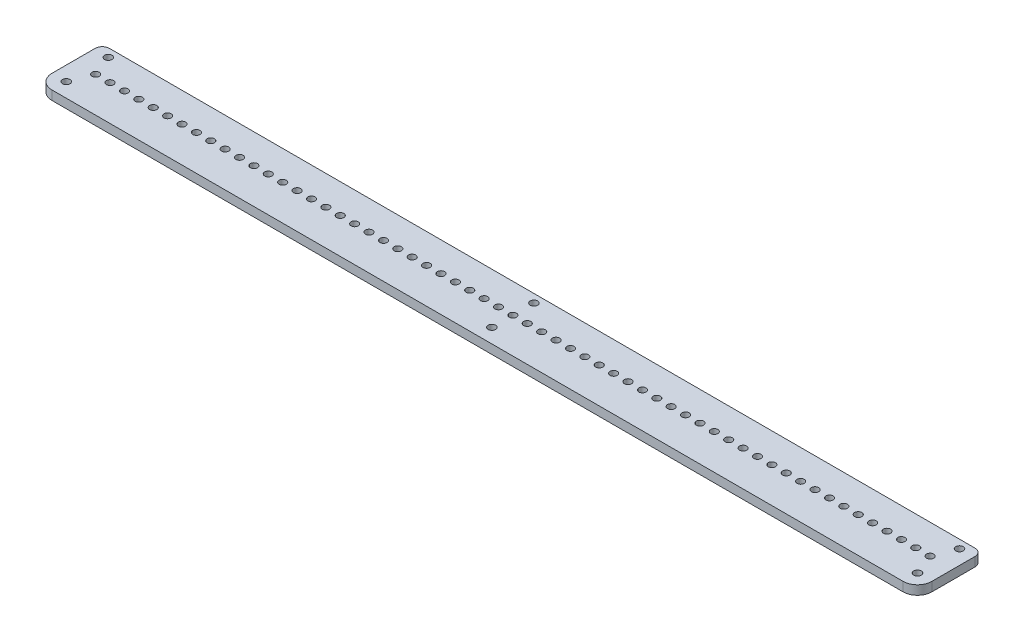
from build123d import *

# Parameters (mm, degrees)
BOSS_EXTRUDE1_DEPTH   = 6.35
M6X1_0_TAPPED_HOLE2_D = 5
LPATTERN2_COUNT       = 59
LPATTERN2_PITCH       = 10
CUT_EXTRUDE1_REACH    = 8.35
SKETCH8_R             = 2.6


with BuildPart() as part:
    # Sketch1 → Boss-Extrude1 (new body)
    with BuildSketch(Plane(origin=(0, 0, 0), x_dir=(1, 0, 0), z_dir=(0, 1, 0))):
        with BuildLine():
            Line((10, 0), (601.6, 0))
            ThreePointArc((601.6, 0), (608.671067812, 2.928932188), (611.6, 10))
            Line((611.6, 10), (611.6, 40))
            ThreePointArc((611.6, 40), (610.135533906, 43.535533906), (606.6, 45))
            Line((606.6, 45), (5, 45))
            ThreePointArc((5, 45), (1.464466094, 43.535533906), (0, 40))
            Line((0, 40), (0, 10))
            ThreePointArc((0, 10), (2.928932188, 2.928932188), (10, 0))
        make_face()
    extrude(amount=BOSS_EXTRUDE1_DEPTH)

    # M6x1.0 Tapped Hole2 (through all)
    with Locations(Plane(origin=(0, 6.35, 0), x_dir=(1, 0, 0), z_dir=(0, 1, 0))):
        with Locations((595.8, 24.6)):
            m6x1_0_tapped_hole2 = Hole(M6X1_0_TAPPED_HOLE2_D / 2)

    # LPattern2: M6x1.0 Tapped Hole2 ×59
    with Locations(*[(-i * LPATTERN2_PITCH, 0, 0) for i in range(1, LPATTERN2_COUNT)]):
        add(m6x1_0_tapped_hole2, mode=Mode.SUBTRACT)

    # Sketch8 → Cut-Extrude1 (cut, up to next)
    with BuildSketch(Plane(origin=(0, 6.35, 0), x_dir=(1, 0, 0), z_dir=(0, 1, 0)), mode=Mode.PRIVATE) as cut_extrude1_sk1:
        with Locations((10, 10)):
            Circle(SKETCH8_R)
    cut_extrude1_tool1 = extrude(cut_extrude1_sk1.sketch, amount=-CUT_EXTRUDE1_REACH, mode=Mode.PRIVATE) & part.part
    add(cut_extrude1_tool1.solids().sort_by_distance((10, 6.35, -10))[0], mode=Mode.SUBTRACT)
    # Sketch8 → Cut-Extrude1 (cut, up to next)
    with BuildSketch(Plane(origin=(0, 6.35, 0), x_dir=(1, 0, 0), z_dir=(0, 1, 0)), mode=Mode.PRIVATE) as cut_extrude1_sk2:
        with Locations((10, 39.2)):
            Circle(SKETCH8_R)
    cut_extrude1_tool2 = extrude(cut_extrude1_sk2.sketch, amount=-CUT_EXTRUDE1_REACH, mode=Mode.PRIVATE) & part.part
    add(cut_extrude1_tool2.solids().sort_by_distance((10, 6.35, -39.2))[0], mode=Mode.SUBTRACT)
    # Sketch8 → Cut-Extrude1 (cut, up to next)
    with BuildSketch(Plane(origin=(0, 6.35, 0), x_dir=(1, 0, 0), z_dir=(0, 1, 0)), mode=Mode.PRIVATE) as cut_extrude1_sk3:
        with Locations((601.6, 10)):
            Circle(SKETCH8_R)
    cut_extrude1_tool3 = extrude(cut_extrude1_sk3.sketch, amount=-CUT_EXTRUDE1_REACH, mode=Mode.PRIVATE) & part.part
    add(cut_extrude1_tool3.solids().sort_by_distance((601.6, 6.35, -10))[0], mode=Mode.SUBTRACT)
    # Sketch8 → Cut-Extrude1 (cut, up to next)
    with BuildSketch(Plane(origin=(0, 6.35, 0), x_dir=(1, 0, 0), z_dir=(0, 1, 0)), mode=Mode.PRIVATE) as cut_extrude1_sk4:
        with Locations((601.6, 39.2)):
            Circle(SKETCH8_R)
    cut_extrude1_tool4 = extrude(cut_extrude1_sk4.sketch, amount=-CUT_EXTRUDE1_REACH, mode=Mode.PRIVATE) & part.part
    add(cut_extrude1_tool4.solids().sort_by_distance((601.6, 6.35, -39.2))[0], mode=Mode.SUBTRACT)
    # Sketch8 → Cut-Extrude1 (cut, up to next)
    with BuildSketch(Plane(origin=(0, 6.35, 0), x_dir=(1, 0, 0), z_dir=(0, 1, 0)), mode=Mode.PRIVATE) as cut_extrude1_sk5:
        with Locations((305.8, 10)):
            Circle(SKETCH8_R)
    cut_extrude1_tool5 = extrude(cut_extrude1_sk5.sketch, amount=-CUT_EXTRUDE1_REACH, mode=Mode.PRIVATE) & part.part
    add(cut_extrude1_tool5.solids().sort_by_distance((305.8, 6.35, -10))[0], mode=Mode.SUBTRACT)
    # Sketch8 → Cut-Extrude1 (cut, up to next)
    with BuildSketch(Plane(origin=(0, 6.35, 0), x_dir=(1, 0, 0), z_dir=(0, 1, 0)), mode=Mode.PRIVATE) as cut_extrude1_sk6:
        with Locations((305.8, 39.2)):
            Circle(SKETCH8_R)
    cut_extrude1_tool6 = extrude(cut_extrude1_sk6.sketch, amount=-CUT_EXTRUDE1_REACH, mode=Mode.PRIVATE) & part.part
    add(cut_extrude1_tool6.solids().sort_by_distance((305.8, 6.35, -39.2))[0], mode=Mode.SUBTRACT)


solid = part.part
